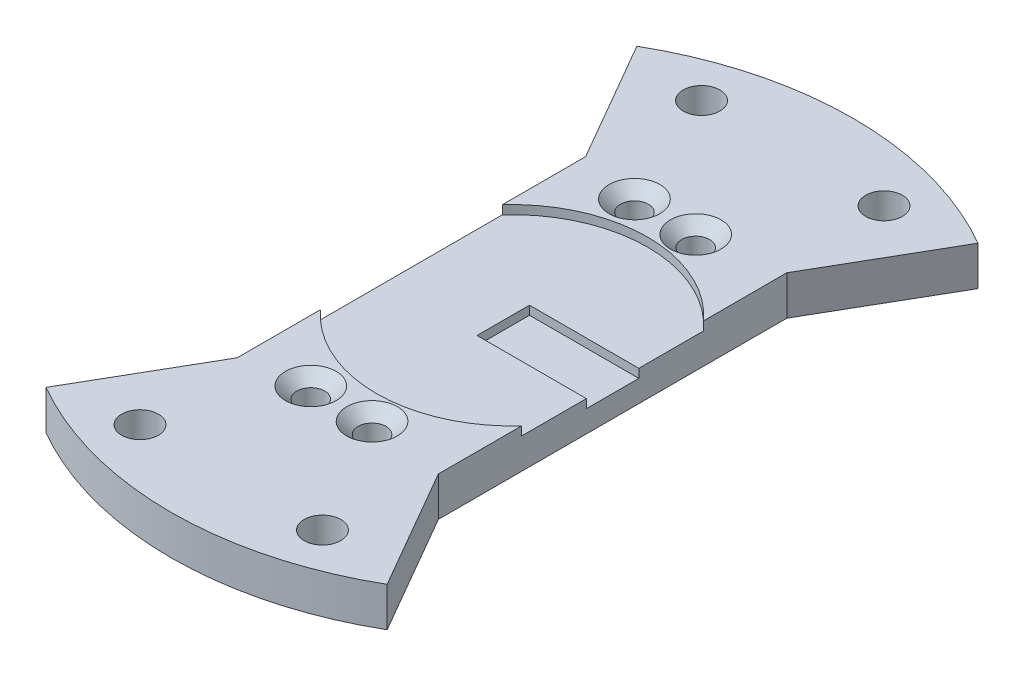
from build123d import *

# Parameters (mm, degrees)
SKETCH1_R                                           = 2.1
BOSS_EXTRUDE1_DEPTH                                 = 4.5
SKETCH2_R                                           = 15.5
CUT_EXTRUDE1_DEPTH                                  = 1
SKETCH3_W                                           = 12.5
SKETCH3_H                                           = 6
CUT_EXTRUDE2_DEPTH                                  = 1
SKETCH4_R                                           = 1.6
CUT_EXTRUDE3_DEPTH                                  = 5.5
CSK_FOR_M4_COUNTERSUNK_FLAT_HEAD_SCREW1_D           = 3.2
CSK_FOR_M4_COUNTERSUNK_FLAT_HEAD_SCREW1_CSINK_D     = 5.8
CSK_FOR_M4_COUNTERSUNK_FLAT_HEAD_SCREW1_CSINK_ANGLE = 90


with BuildPart() as part:
    # Sketch1 → Boss-Extrude1 (new body)
    with BuildSketch(Plane(origin=(0, 0, 0), x_dir=(1, 0, 0), z_dir=(0, 1, 0))):
        with BuildLine():
            Line((11.5, -19.918584287), (0, 0))
            Line((0, 0), (-11.5, -19.918584287))
            Line((-11.5, -19.918584287), (-19.5, -33.774990748))
            ThreePointArc((-19.5, -33.774990748), (0, -39), (19.5, -33.774990748))
            Line((19.5, -33.774990748), (11.5, -19.918584287))
        make_face()
        with Locations((-10.42932356, -32.098157425)):
            Circle(SKETCH1_R, mode=Mode.SUBTRACT)
        with Locations((10.42932356, -32.098157425)):
            Circle(SKETCH1_R, mode=Mode.SUBTRACT)
        Polygon((11.5, 19.918584287), (0, 0), (11.5, -19.918584287), align=None)
        with BuildLine():
            Line((-11.5, 19.918584287), (0, 0))
            Line((0, 0), (11.5, 19.918584287))
            Line((11.5, 19.918584287), (19.5, 33.774990748))
            ThreePointArc((19.5, 33.774990748), (0, 39), (-19.5, 33.774990748))
            Line((-19.5, 33.774990748), (-11.5, 19.918584287))
        make_face()
        with Locations((-10.42932356, 32.098157425)):
            Circle(SKETCH1_R, mode=Mode.SUBTRACT)
        with Locations((10.42932356, 32.098157425)):
            Circle(SKETCH1_R, mode=Mode.SUBTRACT)
        Polygon((-11.5, -19.918584287), (0, 0), (-11.5, 19.918584287), align=None)
    extrude(amount=BOSS_EXTRUDE1_DEPTH)

    # Sketch2 → Cut-Extrude1 (cut)
    with BuildSketch(Plane(origin=(0, 4.5, 0), x_dir=(1, 0, 0), z_dir=(0, 1, 0))):
        Circle(SKETCH2_R)
    extrude(amount=-CUT_EXTRUDE1_DEPTH, mode=Mode.SUBTRACT)

    # Sketch3 → Cut-Extrude2 (cut)
    with BuildSketch(Plane(origin=(0, 3.5, 0), x_dir=(1, 0, 0), z_dir=(0, 1, 0))):
        with Locations((5.25, 0)):
            Rectangle(SKETCH3_W, SKETCH3_H)
    extrude(amount=-CUT_EXTRUDE2_DEPTH, mode=Mode.SUBTRACT)

    # Sketch4 → Cut-Extrude3 (cut, through all)
    with BuildSketch(Plane(origin=(0, 4.5, 0), x_dir=(1, 0, 0), z_dir=(0, 1, 0))):
        with Locations((-4.5, -18.5)):
            Circle(SKETCH4_R)
        with Locations((2.5, -18.5)):
            Circle(SKETCH4_R)
        with Locations((-4.5, 18.5)):
            Circle(SKETCH4_R)
        with Locations((2.5, 18.5)):
            Circle(SKETCH4_R)
    extrude(amount=-CUT_EXTRUDE3_DEPTH, mode=Mode.SUBTRACT)

    # CSK for M4 Countersunk Flat Head Screw1 (through all)
    with Locations(Plane(origin=(-4.5, 4.5, 18.5), x_dir=(0, 0, 1), z_dir=(0, 1, 0))):
        with Locations((0, 0), (0, 7), (-37, 0), (-37, 7)):
            CounterSinkHole(CSK_FOR_M4_COUNTERSUNK_FLAT_HEAD_SCREW1_D / 2, CSK_FOR_M4_COUNTERSUNK_FLAT_HEAD_SCREW1_CSINK_D / 2, counter_sink_angle=CSK_FOR_M4_COUNTERSUNK_FLAT_HEAD_SCREW1_CSINK_ANGLE)


solid = part.part
